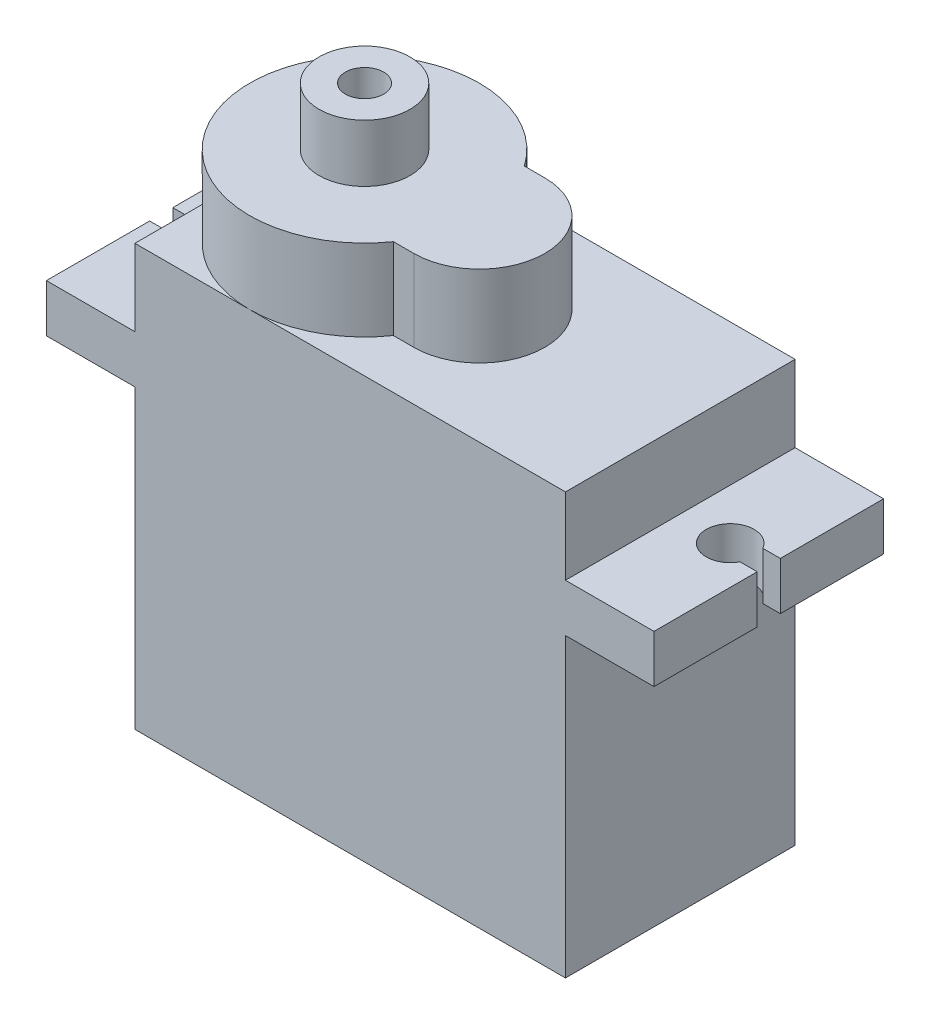
from build123d import *

# Parameters (mm, degrees)
SKETCH1_W           = 22.86
SKETCH1_H           = 12.192
BOSS_EXTRUDE1_DEPTH = 22.352
BOSS_EXTRUDE2_DEPTH = 4.318
BOSS_EXTRUDE3_START = -15.748
BOSS_EXTRUDE3_DEPTH = 2.54
SKETCH4_R           = 2.413
SKETCH4_R_2         = 1.016
BOSS_EXTRUDE4_DEPTH = 3.048


with BuildPart() as part:
    # Sketch1 → Boss-Extrude1 (new body)
    with BuildSketch(Plane(origin=(0, 0, 0), x_dir=(1, 0, 0), z_dir=(0, 1, 0))):
        Rectangle(SKETCH1_W, SKETCH1_H)
    extrude(amount=BOSS_EXTRUDE1_DEPTH)

    # Sketch2 → Boss-Extrude2 (add)
    with BuildSketch(Plane(origin=(0, 22.352, 0), x_dir=(1, 0, 0), z_dir=(0, 1, 0))):
        with BuildLine():
            Line((0.762, 3.475776023), (-0.325986717, 3.475776023))
            ThreePointArc((-0.325986717, 3.475776023), (-11.43, 0), (-0.325986717, -3.475776023))
            Line((-0.325986717, -3.475776023), (0.762, -3.475776023))
            ThreePointArc((0.762, -3.475776023), (4.237776023, 0), (0.762, 3.475776023))
        make_face()
    extrude(amount=BOSS_EXTRUDE2_DEPTH)

    # Sketch3 → Boss-Extrude3 (add)
    with BuildSketch(Plane.XZ.offset(BOSS_EXTRUDE3_START)):
        with BuildLine():
            Line((-16.129, -6.096), (16.129, -6.096))
            Line((16.129, -6.096), (16.129, -0.613485199))
            Line((16.129, -0.613485199), (15.199445863, -0.613485199))
            ThreePointArc((15.199445863, -0.613485199), (12.827148451, 0.036418828), (15.218207768, 0.613485199))
            Line((15.218207768, 0.613485199), (16.129, 0.613485199))
            Line((16.129, 0.613485199), (16.129, 6.096))
            Line((16.129, 6.096), (-16.129, 6.096))
            Line((-16.129, 6.096), (-16.129, 0.613485199))
            Line((-16.129, 0.613485199), (-15.218207768, 0.613485199))
            ThreePointArc((-15.218207768, 0.613485199), (-12.827148451, 0.036418828), (-15.199445863, -0.613485199))
            Line((-15.199445863, -0.613485199), (-16.129, -0.613485199))
            Line((-16.129, -0.613485199), (-16.129, -6.096))
        make_face()
    extrude(amount=-BOSS_EXTRUDE3_DEPTH)

    # Sketch4 → Boss-Extrude4 (add)
    with BuildSketch(Plane(origin=(0, 26.67, 0), x_dir=(1, 0, 0), z_dir=(0, 1, 0))):
        with Locations((-5.334, 0)):
            Circle(SKETCH4_R)
        with Locations((-5.334, 0)):
            Circle(SKETCH4_R_2, mode=Mode.SUBTRACT)
    extrude(amount=BOSS_EXTRUDE4_DEPTH)


solid = part.part
